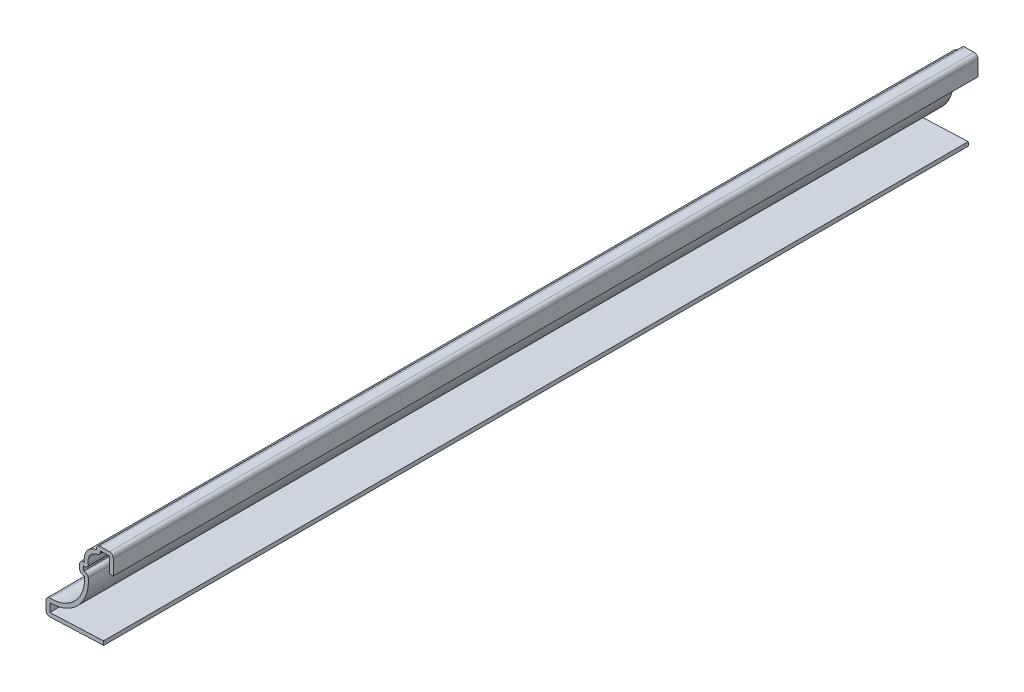
from build123d import *

# Parameters (mm, degrees)
EXTRUDE_THIN1_DEPTH = 285.75
FILLET1_R           = 1.27


with BuildPart() as part:
    # Sketch1 → Extrude-Thin1 (new body)
    with BuildSketch(Plane.XY):
        with BuildLine():
            Line((0, 0), (-19.05, -0.79375))
            Line((-19.05, -0.79375), (-19.05, 4.7625))
            ThreePointArc((-19.05, 4.7625), (-9.824616787, 7.648549572), (-6.35, 16.66875))
            Line((-6.35, 16.66875), (-7.9375, 16.66875))
            Line((-7.9375, 16.66875), (-7.9375, 20.6375))
            Line((-7.9375, 20.6375), (-6.35, 20.6375))
            ThreePointArc((-6.35, 20.6375), (-5.539033157, 24.253773684), (-2.38125, 26.19375))
            Line((-2.38125, 26.19375), (-2.38125, 27.78125))
            Line((-2.38125, 27.78125), (3.175, 27.78125))
            Line((3.175, 27.78125), (3.175, 21.43125))
            Line((3.175, 21.43125), (1.905, 21.43125))
            Line((1.905, 21.43125), (1.905, 26.51125))
            Line((1.905, 26.51125), (-1.11125, 26.51125))
            Line((-1.11125, 26.51125), (-1.11125, 24.934167832))
            ThreePointArc((-1.11125, 24.934167832), (-4.660969167, 23.278250334), (-4.440513376, 19.3675))
            Line((-4.440513376, 19.3675), (-6.6675, 19.3675))
            Line((-6.6675, 19.3675), (-6.6675, 17.93875))
            Line((-6.6675, 17.93875), (-5.236398958, 17.93875))
            ThreePointArc((-5.236398958, 17.93875), (-8.043524077, 7.673709188), (-17.78, 3.378124142))
            Line((-17.78, 3.378124142), (-17.78, 0.530268619))
            Line((-17.78, 0.530268619), (-0.052870792, 1.268899003))
            Line((-0.052870792, 1.268899003), (0, 0))
        make_face()
    extrude(amount=-EXTRUDE_THIN1_DEPTH)

    # Fillet1
    fillet1_edges = [part.edges().sort_by_distance(p)[0] for p in [
        (-1.11125, 24.934167832, -142.875),
        (-4.440513376, 19.3675, -142.875),
        (-5.236398958, 17.93875, -142.875),
        (-19.05, -0.79375, -142.875),
        (-19.05, 4.7625, -142.875),
        (-7.9375, 16.66875, -142.875),
        (-7.9375, 20.6375, -142.875),
        (-2.38125, 27.78125, -142.875),
        (3.175, 27.78125, -142.875),
    ]]
    fillet(fillet1_edges, radius=FILLET1_R)


solid = part.part
